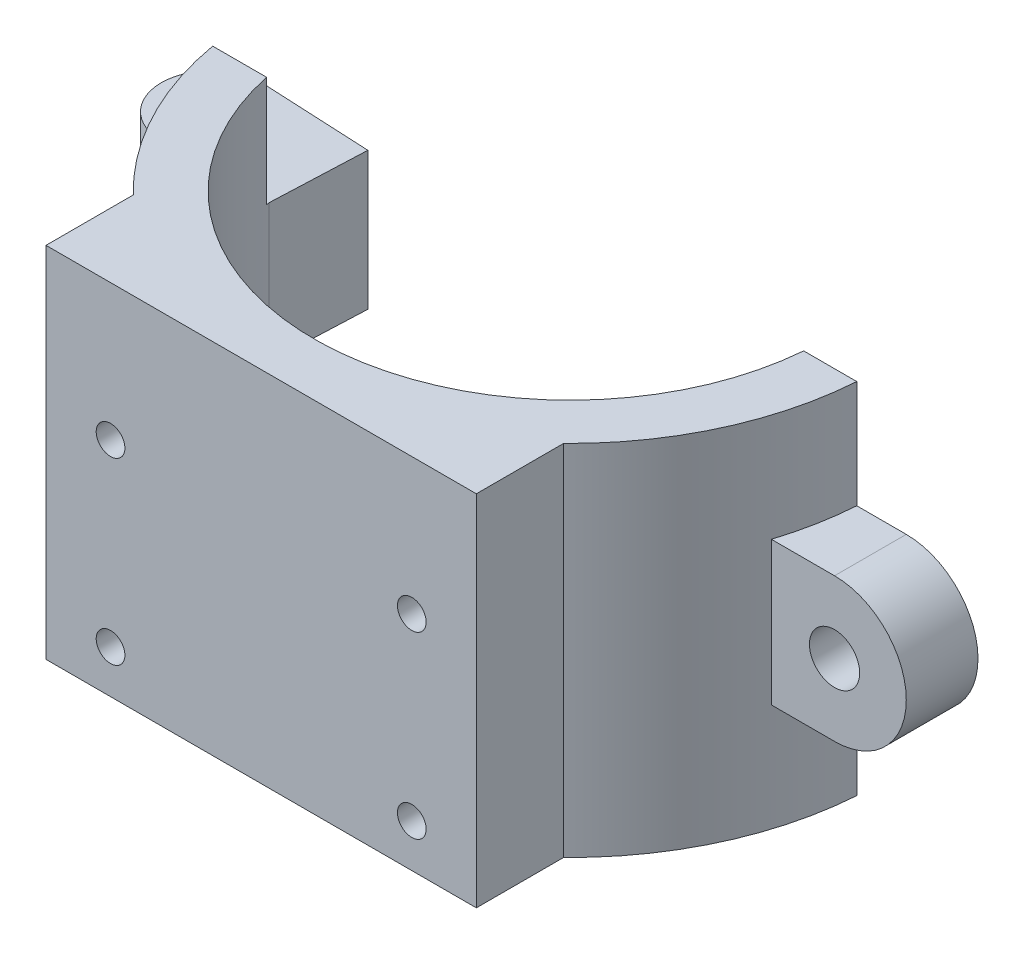
from build123d import *

# Parameters (mm, degrees)
BOSS_EXTRU_1_DEPTH      = 25
ESQUISSE2_R             = 1.5
BOSS_EXTRU_2_DEPTH      = 9.8
ESQUISSE3_W             = 31.176753694
ESQUISSE3_H             = 17.849543287
ENL_V_MAT_EXTRU_2_DEPTH = 0.2
ESQUISSE4_R             = 1.75
BOSS_EXTRU_3_DEPTH      = 5
ESQUISSE5_W             = 14.938362126
ESQUISSE5_H             = 3.694178454
ENL_V_MAT_EXTRU_3_DEPTH = 7.7
ESQUISSE6_W             = 7.972464104
ESQUISSE6_H             = 3.417362688
ENL_V_MAT_EXTRU_4_DEPTH = 7.7
BOSS_EXTRU_4_DEPTH      = 25
ESQUISSE8_R             = 1
ENL_V_MAT_EXTRU_5_DEPTH = 5


with BuildPart() as part:
    # Esquisse1 → Boss.-Extru.1 (new body)
    with BuildSketch(Plane(origin=(0, 0, 0), x_dir=(1, 0, 0), z_dir=(0, 1, 0))):
        with BuildLine():
            Line((17.783419244, -3), (21.484005679, -3))
            ThreePointArc((21.484005679, -3), (1.006821565, -23.012759245), (-21.25, -5))
            Line((-21.25, -5), (-17.5, -5))
            ThreePointArc((-17.5, -5), (1.009990899, -19.317966169), (17.783419244, -3))
        make_face()
    extrude(amount=-BOSS_EXTRU_1_DEPTH)

    # Esquisse2 → Boss.-Extru.2 (add)
    with BuildSketch(Plane(origin=(0, -17.5, 0), x_dir=(1, 0, 0), z_dir=(0, 1, 0))):
        with BuildLine():
            Line((-17.5, -5), (-25, -5))
            ThreePointArc((-25, -5), (-28.5, -1.5), (-25, 2))
            Line((-25, 2), (-17.219475506, 1.620843362))
            Line((-17.219475506, 1.620843362), (-17.5, -5))
        make_face()
        with Locations((-25, -1.5)):
            Circle(ESQUISSE2_R, mode=Mode.SUBTRACT)
    extrude(amount=BOSS_EXTRU_2_DEPTH)

    # Esquisse3 → Enlèv. mat.-Extru.2 (cut)
    with BuildSketch(Plane.XZ.offset(17.5)):
        with Locations((-26.283313767, -3.924771644)):
            Rectangle(ESQUISSE3_W, ESQUISSE3_H)
    extrude(amount=-ENL_V_MAT_EXTRU_2_DEPTH, mode=Mode.SUBTRACT)

    # Esquisse4 → Boss.-Extru.3 (add)
    with BuildSketch(Plane(origin=(0, 0, 3), x_dir=(-1, 0, 0), z_dir=(0, 0, -1))):
        with BuildLine():
            Line((-17.783419244, -17.5), (-24.935595774, -17.5))
            ThreePointArc((-24.935595774, -17.5), (-29.935595774, -12.5), (-24.935595774, -7.5))
            Line((-24.935595774, -7.5), (-17.783419244, -7.5))
            Line((-17.783419244, -7.5), (-17.783419244, -17.5))
        make_face()
        with Locations((-24.935595774, -12.5)):
            Circle(ESQUISSE4_R, mode=Mode.SUBTRACT)
    extrude(amount=-BOSS_EXTRU_3_DEPTH)

    # Esquisse5 → Enlèv. mat.-Extru.3 (cut)
    with BuildSketch(Plane(origin=(0, 0, 0), x_dir=(1, 0, 0), z_dir=(0, 1, 0))):
        with Locations((-16.074576592, -3.352910773)):
            Rectangle(ESQUISSE5_W, ESQUISSE5_H)
    extrude(amount=-ENL_V_MAT_EXTRU_3_DEPTH, mode=Mode.SUBTRACT)

    # Esquisse6 → Enlèv. mat.-Extru.4 (cut)
    with BuildSketch(Plane.XZ.offset(25)):
        with Locations((-19.148660485, 3.491318656)):
            Rectangle(ESQUISSE6_W, ESQUISSE6_H)
    extrude(amount=-ENL_V_MAT_EXTRU_4_DEPTH, mode=Mode.SUBTRACT)

    # Esquisse7 → Boss.-Extru.4 (add)
    with BuildSketch(Plane(origin=(0, 0, 0), x_dir=(1, 0, 0), z_dir=(0, 1, 0))):
        with BuildLine():
            Line((15, -11.169539803), (15, -23.036306554))
            Line((15, -23.036306554), (-15, -23.036306554))
            Line((-15, -23.036306554), (-15, -11.169539803))
            ThreePointArc((-15, -11.169539803), (0, -19.346568298), (15, -11.169539803))
        make_face()
    extrude(amount=-BOSS_EXTRU_4_DEPTH)

    # Esquisse8 → Enlèv. mat.-Extru.5 (cut)
    with BuildSketch(Plane.XY.offset(23.036306554)):
        with Locations((10.5, -22)):
            Circle(ESQUISSE8_R)
        with Locations((-10.5, -22)):
            Circle(ESQUISSE8_R)
        with Locations((10.5, -9.5)):
            Circle(ESQUISSE8_R)
        with Locations((-10.5, -9.5)):
            Circle(ESQUISSE8_R)
    extrude(amount=-ENL_V_MAT_EXTRU_5_DEPTH, mode=Mode.SUBTRACT)


solid = part.part
